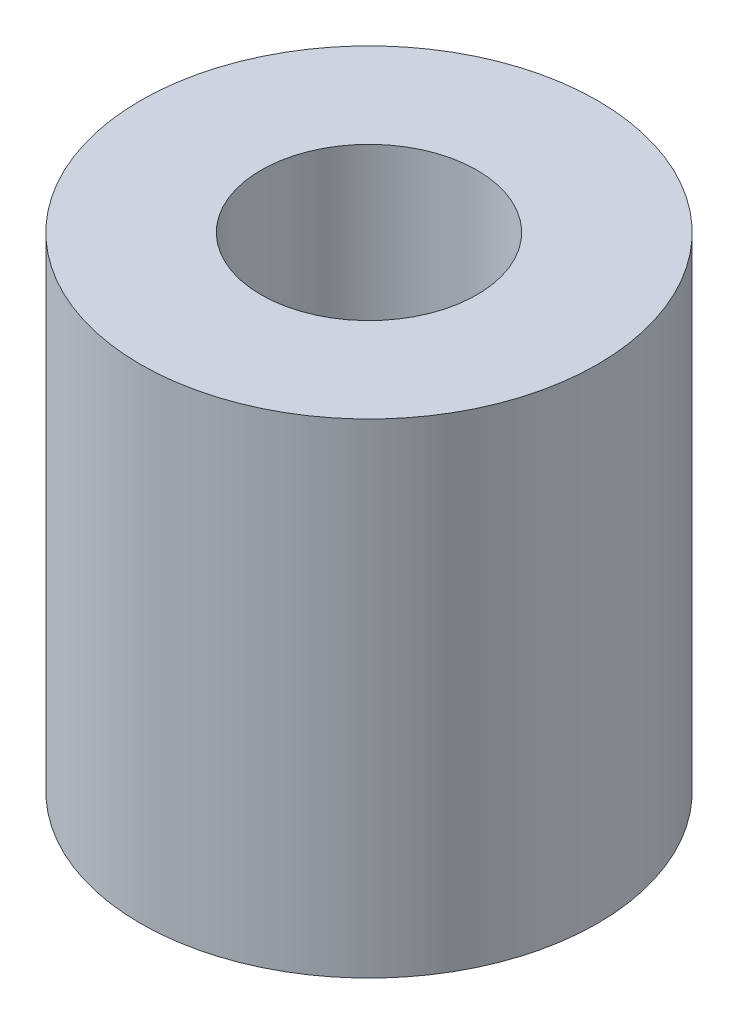
from build123d import *

# Parameters (mm, degrees)
SKETCH1_R           = 4.55
SKETCH1_R_2         = 2.15
BOSS_EXTRUDE1_DEPTH = 9.64


with BuildPart() as part:
    # Sketch1 → Boss-Extrude1 (new body)
    with BuildSketch(Plane(origin=(0, 0, 0), x_dir=(1, 0, 0), z_dir=(0, 1, 0))):
        Circle(SKETCH1_R)
        Circle(SKETCH1_R_2, mode=Mode.SUBTRACT)
    extrude(amount=BOSS_EXTRUDE1_DEPTH)


solid = part.part
